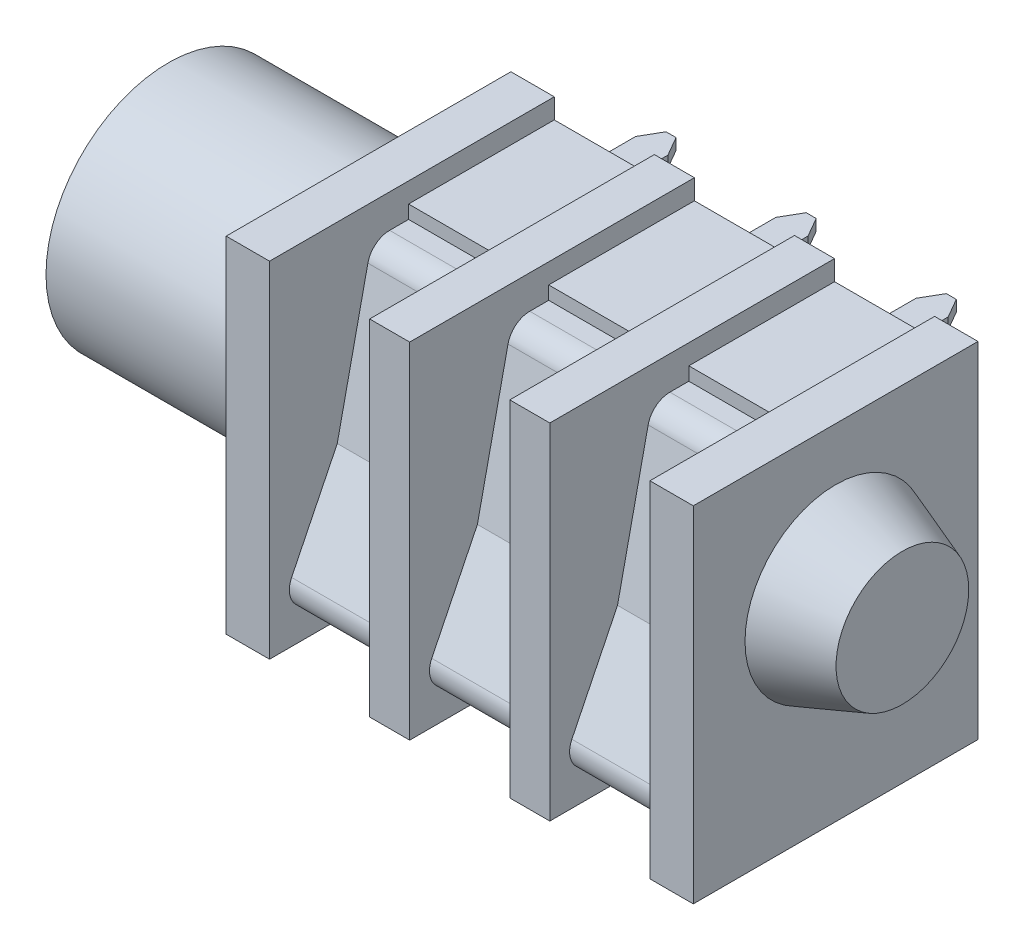
from build123d import *

# Parameters (mm, degrees)
SKETCH1_W                          = 12.8
SKETCH1_H                          = 15.5
BOSS_EXTRUDE1_DEPTH                = 21
SKETCH2_R                          = 5.5
SKETCH2_R_2                        = 3.2
BOSS_EXTRUDE2_DEPTH                = 9
SKETCH3_R                          = 4.075
BOSS_EXTRUDE3_DEPTH                = 3
BOSS_EXTRUDE3_TAPER                = 20
SKETCH6_W                          = 4.5
SKETCH6_H                          = 6.25
CUT_EXTRUDE1_DEPTH                 = 15.5
SKETCH7_W                          = 4.5
SKETCH7_H                          = 0.9
CUT_EXTRUDE2_DEPTH                 = 9
LPATTERN1_COUNT                    = 3
LPATTERN1_PITCH                    = 6.3
EXTRUDE_THIN1_DEPTH                = 2.25
SKETCH9_W                          = 3
SKETCH9_H                          = 0.5
EXTRUDE_THIN2_DEPTH                = 0.725
CHAMFER1_SIZE                      = 0.5
CHAMFER1_SIZE2                     = 0.866025404
CHAMFER1_PART_2_SIZE               = 0.5
CHAMFER1_PART_2_SIZE2              = 0.866025404
LPATTERN2_COUNT                    = 3
LPATTERN2_PITCH                    = 6.3
CHAMFER1_OF_LPATTERN2_SIZE2        = 0.5
CHAMFER1_OF_LPATTERN2_SIZE         = 0.866025404
CHAMFER1_PART_2_OF_LPATTERN2_SIZE2 = 0.5
CHAMFER1_PART_2_OF_LPATTERN2_SIZE  = 0.866025404


with BuildPart() as part:
    # Sketch1 → Boss-Extrude1 (new body)
    with BuildSketch(Plane(origin=(0, 0, 0), x_dir=(0, 0, -1), z_dir=(1, 0, 0))):
        with Locations((6.4, 7.75)):
            Rectangle(SKETCH1_W, SKETCH1_H)
    extrude(amount=BOSS_EXTRUDE1_DEPTH)

    # Sketch2 → Boss-Extrude2 (add)
    with BuildSketch(Plane.ZY):
        with Locations((-6.4, 9.05)):
            Circle(SKETCH2_R)
        with Locations((-6.4, 9.05)):
            Circle(SKETCH2_R_2, mode=Mode.SUBTRACT)
    extrude(amount=BOSS_EXTRUDE2_DEPTH)

    # Sketch3 → Boss-Extrude3 (add)
    with BuildSketch(Plane(origin=(21, 0, 0), x_dir=(0, 0, -1), z_dir=(1, 0, 0))):
        with Locations((6.4, 9.05)):
            Circle(SKETCH3_R)
    extrude(amount=BOSS_EXTRUDE3_DEPTH, taper=BOSS_EXTRUDE3_TAPER)

    # Sketch6 → Cut-Extrude1 (cut)
    with BuildSketch(Plane.XZ):
        with Locations((4.2, -3.125)):
            Rectangle(SKETCH6_W, SKETCH6_H)
    cut_extrude1 = extrude(amount=-CUT_EXTRUDE1_DEPTH, mode=Mode.SUBTRACT)

    # Sketch7 → Cut-Extrude2 (cut)
    with BuildSketch(Plane(origin=(0, 0, -12.8), x_dir=(-1, 0, 0), z_dir=(0, 0, -1))):
        with Locations((-4.2, 15.05)):
            Rectangle(SKETCH7_W, SKETCH7_H)
        with Locations((-4.2, 0.45)):
            Rectangle(SKETCH7_W, SKETCH7_H)
    cut_extrude2 = extrude(amount=-CUT_EXTRUDE2_DEPTH, mode=Mode.SUBTRACT)

    # LPattern1: Cut-Extrude1, Cut-Extrude2 ×3
    with Locations(*[(i * LPATTERN1_PITCH, 0, 0) for i in range(1, LPATTERN1_COUNT)]):
        add(cut_extrude1, mode=Mode.SUBTRACT)
        add(cut_extrude2, mode=Mode.SUBTRACT)

    # Sketch8 → Extrude-Thin1 (add, symmetric)
    with BuildSketch(Plane.ZY.offset(-4.2)):
        with BuildLine():
            Line((-6.25, 13.5), (-5.398229918, 13.5))
            ThreePointArc((-5.398229918, 13.5), (-5.084448593, 13.389283033), (-4.909630934, 13.106165118))
            Line((-4.909630934, 13.106165118), (-3.519996024, 6.710710403))
            Line((-3.519996024, 6.710710403), (-1.441008044, 2.470100604))
            ThreePointArc((-1.441008044, 2.470100604), (-1.465663914, 1.985472404), (-1.889957622, 1.75))
            Line((-1.889957622, 1.75), (-6.25, 1.75))
            Line((-6.25, 1.75), (-6.25, 1.25))
            Line((-6.25, 1.25), (-1.889957622, 1.25))
            ThreePointArc((-1.889957622, 1.25), (-1.041370205, 1.720944808), (-0.992058465, 2.690201208))
            Line((-0.992058465, 2.690201208), (-3.044298744, 6.876252459))
            Line((-3.044298744, 6.876252459), (-4.421031949, 13.212330236))
            ThreePointArc((-4.421031949, 13.212330236), (-4.770667267, 13.778566065), (-5.398229918, 14))
            Line((-5.398229918, 14), (-6.25, 14))
            Line((-6.25, 14), (-6.25, 13.5))
        make_face()
    extrude_thin1 = extrude(amount=EXTRUDE_THIN1_DEPTH, both=True)

    # Sketch9 → Extrude-Thin2 (add, symmetric)
    with BuildSketch(Plane.ZY.offset(-4.2)):
        with Locations((-14.3, 13.4)):
            Rectangle(SKETCH9_W, SKETCH9_H)
        with Locations((-14.3, 2.1)):
            Rectangle(SKETCH9_W, SKETCH9_H)
    extrude_thin2 = extrude(amount=EXTRUDE_THIN2_DEPTH, both=True)

    # Chamfer1
    chamfer1_edges = [part.edges().sort_by_distance(p)[0] for p in [
        (3.475, 13.4, -15.8),
        (4.925, 13.4, -15.8),
    ]]
    chamfer1_side = [part.faces().sort_by_distance(p)[0] for p in [
        (4.2, 13.4, -15.8),
    ]]
    chamfer(chamfer1_edges, length=CHAMFER1_SIZE, length2=CHAMFER1_SIZE2, reference=chamfer1_side[0])

    # Chamfer1 part 2
    chamfer1_part_2_edges = [part.edges().sort_by_distance(p)[0] for p in [
        (3.475, 2.1, -15.8),
        (4.925, 2.1, -15.8),
    ]]
    chamfer1_part_2_side = [part.faces().sort_by_distance(p)[0] for p in [
        (4.2, 2.1, -15.8),
    ]]
    chamfer(chamfer1_part_2_edges, length=CHAMFER1_PART_2_SIZE, length2=CHAMFER1_PART_2_SIZE2, reference=chamfer1_part_2_side[0])

    # LPattern2: Extrude-Thin1, Extrude-Thin2 ×3
    with Locations(*[(i * LPATTERN2_PITCH, 0, 0) for i in range(1, LPATTERN2_COUNT)]):
        add(extrude_thin1)
        add(extrude_thin2)

    # Chamfer1 of LPattern2
    chamfer1_of_lpattern2_edges = [part.edges().sort_by_distance(p)[0] for p in [
        (9.775, 13.4, -15.8),
        (11.225, 13.4, -15.8),
        (16.075, 13.4, -15.8),
        (17.525, 13.4, -15.8),
    ]]
    chamfer(chamfer1_of_lpattern2_edges, length=CHAMFER1_OF_LPATTERN2_SIZE, length2=CHAMFER1_OF_LPATTERN2_SIZE2)

    # Chamfer1 part 2 of LPattern2
    chamfer1_part_2_of_lpattern2_edges = [part.edges().sort_by_distance(p)[0] for p in [
        (9.775, 2.1, -15.8),
        (11.225, 2.1, -15.8),
        (16.075, 2.1, -15.8),
        (17.525, 2.1, -15.8),
    ]]
    chamfer(chamfer1_part_2_of_lpattern2_edges, length=CHAMFER1_PART_2_OF_LPATTERN2_SIZE, length2=CHAMFER1_PART_2_OF_LPATTERN2_SIZE2)


solid = part.part
